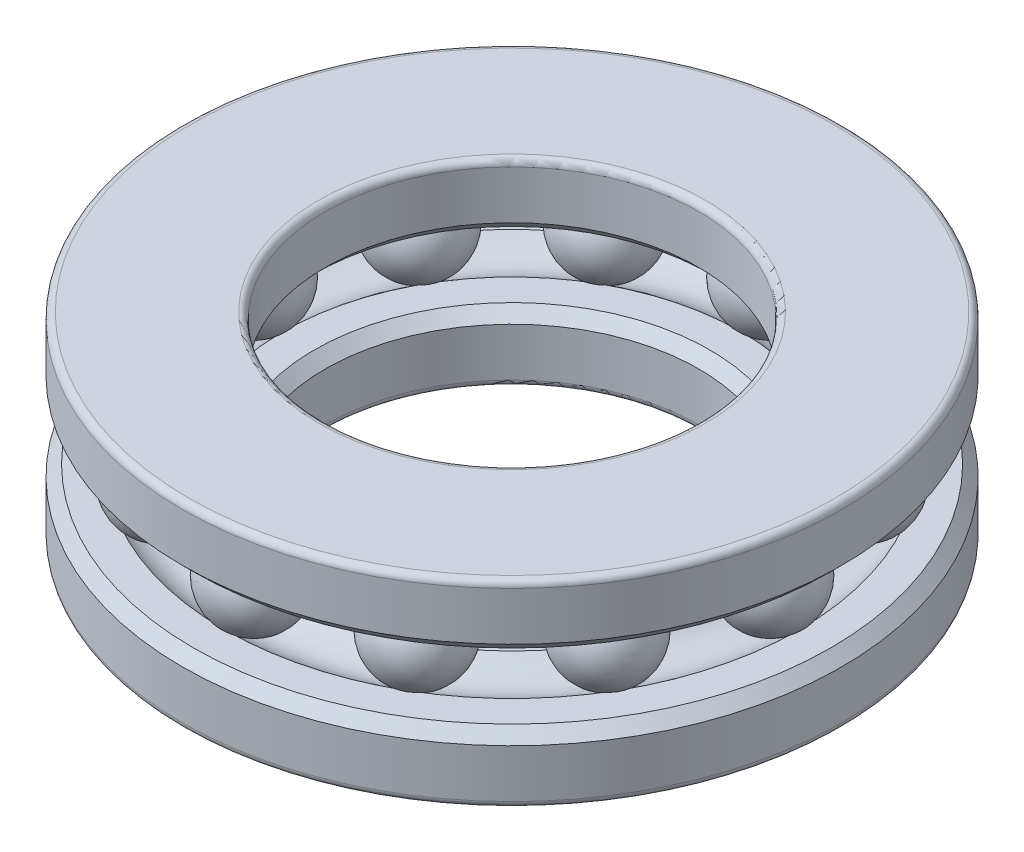
from build123d import *

# Parameters (mm, degrees)
FILLET1_R         = 0.3
FILLET2_R         = 0.3
CHAMFER1_SIZE     = 0.5
CHAMFER2_SIZE     = 0.5
CIRPATTERN1_COUNT = 12


with BuildPart() as part:
    # Sketch1 → Revolve1 (revolve)
    with BuildSketch(Plane(origin=(0, 0, 0), x_dir=(0, 0, -1), z_dir=(1, 0, 0))):
        with BuildLine():
            Line((-15, -1.5), (-15, -4.5))
            Line((-15, -4.5), (-8.5, -4.5))
            Line((-8.5, -4.5), (-8.5, -1.5))
            Line((-8.5, -1.5), (-10.427124344, -1.5))
            ThreePointArc((-10.427124344, -1.5), (-11.75, -2), (-13.072875656, -1.5))
            Line((-13.072875656, -1.5), (-15, -1.5))
        make_face()
        with BuildLine():
            Line((-15, 1.5), (-13.072875656, 1.5))
            ThreePointArc((-13.072875656, 1.5), (-11.75, 2), (-10.427124344, 1.5))
            Line((-10.427124344, 1.5), (-8.5, 1.5))
            Line((-8.5, 1.5), (-8.5, 4.5))
            Line((-8.5, 4.5), (-15, 4.5))
            Line((-15, 4.5), (-15, 1.5))
        make_face()
    revolve(axis=Axis((0, 0, 0), (0, 1, 0)))

    # Fillet1
    fillet1_edges = [part.edges().sort_by_distance(p)[0] for p in [
        (0, 4.5, -15),
        (0, 4.5, -8.5),
    ]]
    fillet(fillet1_edges, radius=FILLET1_R)

    # Fillet2
    fillet2_edges = [part.edges().sort_by_distance(p)[0] for p in [
        (0, -4.5, -8.5),
        (0, -4.5, -15),
    ]]
    fillet(fillet2_edges, radius=FILLET2_R)

    # Chamfer1
    chamfer1_edges = [part.edges().sort_by_distance(p)[0] for p in [
        (0, 1.5, -15),
        (0, 1.5, -8.5),
    ]]
    chamfer(chamfer1_edges, length=CHAMFER1_SIZE)

    # Chamfer2
    chamfer2_edges = [part.edges().sort_by_distance(p)[0] for p in [
        (0, -1.5, -8.5),
        (0, -1.5, -15),
    ]]
    chamfer(chamfer2_edges, length=CHAMFER2_SIZE)


with BuildPart() as body_2:
    # Sketch3 → Revolve12 (revolve)
    with BuildSketch(Plane(origin=(0, 0, 0), x_dir=(0, 0, -1), z_dir=(1, 0, 0))):
        with BuildLine():
            Line((-11.75, 2.05), (-11.75, -2.05))
            ThreePointArc((-11.75, -2.05), (-9.7, 0), (-11.75, 2.05))
        make_face()
    revolve(axis=Axis((0, 0, 11.75), (0, 1, 0)))


with BuildPart() as cirpattern1_1:
    # CirPattern1: pattern copy
    add(body_2.part.rotate(Axis((0, 0, 0), (0, 1, 0)), 1 * 360 / CIRPATTERN1_COUNT))


with BuildPart() as cirpattern1_2:
    # CirPattern1: pattern copy
    add(body_2.part.rotate(Axis((0, 0, 0), (0, 1, 0)), 2 * 360 / CIRPATTERN1_COUNT))


with BuildPart() as cirpattern1_3:
    # CirPattern1: pattern copy
    add(body_2.part.rotate(Axis((0, 0, 0), (0, 1, 0)), 3 * 360 / CIRPATTERN1_COUNT))


with BuildPart() as cirpattern1_4:
    # CirPattern1: pattern copy
    add(body_2.part.rotate(Axis((0, 0, 0), (0, 1, 0)), 4 * 360 / CIRPATTERN1_COUNT))


with BuildPart() as cirpattern1_5:
    # CirPattern1: pattern copy
    add(body_2.part.rotate(Axis((0, 0, 0), (0, 1, 0)), 5 * 360 / CIRPATTERN1_COUNT))


with BuildPart() as cirpattern1_6:
    # CirPattern1: pattern copy
    add(body_2.part.rotate(Axis((0, 0, 0), (0, 1, 0)), 6 * 360 / CIRPATTERN1_COUNT))


with BuildPart() as cirpattern1_7:
    # CirPattern1: pattern copy
    add(body_2.part.rotate(Axis((0, 0, 0), (0, 1, 0)), 7 * 360 / CIRPATTERN1_COUNT))


with BuildPart() as cirpattern1_8:
    # CirPattern1: pattern copy
    add(body_2.part.rotate(Axis((0, 0, 0), (0, 1, 0)), 8 * 360 / CIRPATTERN1_COUNT))


with BuildPart() as cirpattern1_9:
    # CirPattern1: pattern copy
    add(body_2.part.rotate(Axis((0, 0, 0), (0, 1, 0)), 9 * 360 / CIRPATTERN1_COUNT))


with BuildPart() as cirpattern1_10:
    # CirPattern1: pattern copy
    add(body_2.part.rotate(Axis((0, 0, 0), (0, 1, 0)), 10 * 360 / CIRPATTERN1_COUNT))


with BuildPart() as cirpattern1_11:
    # CirPattern1: pattern copy
    add(body_2.part.rotate(Axis((0, 0, 0), (0, 1, 0)), 11 * 360 / CIRPATTERN1_COUNT))


solid = Compound([part.part, body_2.part, cirpattern1_1.part, cirpattern1_2.part, cirpattern1_3.part, cirpattern1_4.part, cirpattern1_5.part, cirpattern1_6.part, cirpattern1_7.part, cirpattern1_8.part, cirpattern1_9.part, cirpattern1_10.part, cirpattern1_11.part])
